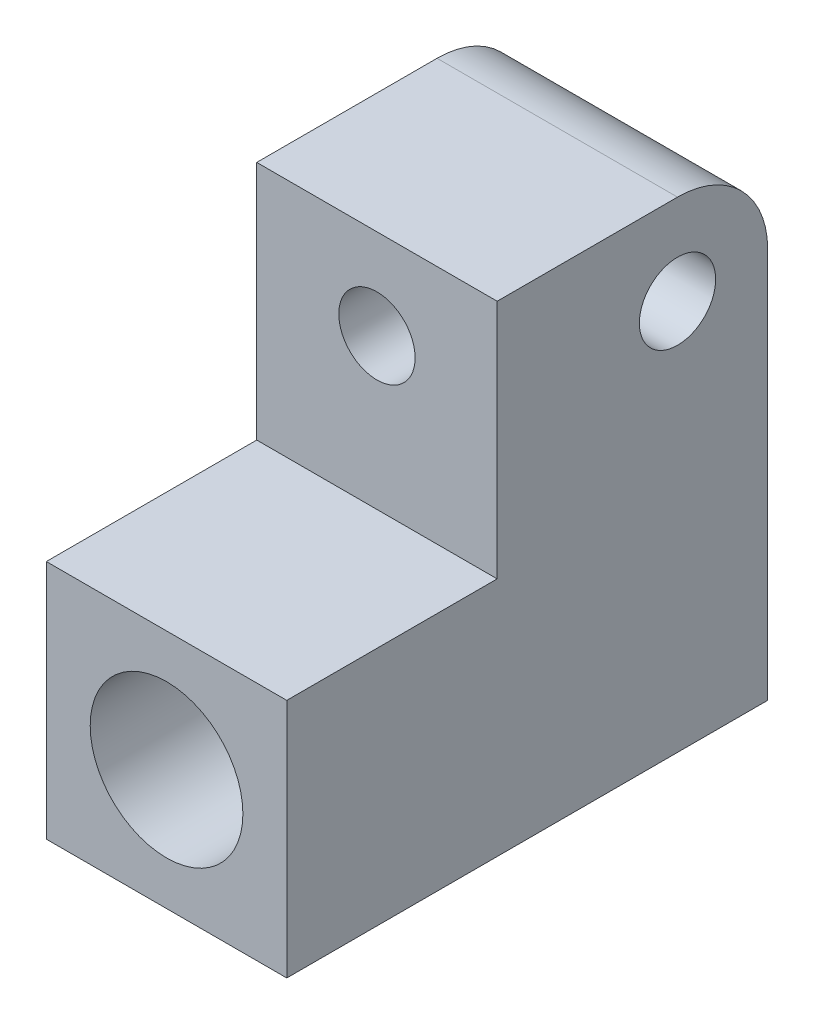
from build123d import *

# Parameters (mm, degrees)
SKETCH3_W           = 20
SKETCH3_H           = 40
BOSS_EXTRUDE2_DEPTH = 20
FILLET2_R           = 7.5
SKETCH4_R           = 3.175
CUT_EXTRUDE2_DEPTH  = 21
SKETCH5_W           = 20
SKETCH5_H           = 17.5
CUT_EXTRUDE3_DEPTH  = 20
CUT_EXTRUDE4_REACH  = 24.5
SKETCH6_R           = 3.175
SKETCH7_R           = 6.35
CUT_EXTRUDE5_DEPTH  = 41


with BuildPart() as part:
    # Sketch3 → Boss-Extrude2 (new body, symmetric)
    with BuildSketch(Plane(origin=(0, 0, 0), x_dir=(1, 0, 0), z_dir=(0, 1, 0))):
        Rectangle(SKETCH3_W, SKETCH3_H)
    extrude(amount=BOSS_EXTRUDE2_DEPTH, both=True)

    # Fillet2
    fillet2_edges = [part.edges().sort_by_distance(p)[0] for p in [
        (0, 20, -20),
    ]]
    fillet(fillet2_edges, radius=FILLET2_R)

    # Sketch4 → Cut-Extrude2 (cut, through all)
    with BuildSketch(Plane.ZY.offset(10)):
        with Locations((-12.5, 12.5)):
            Circle(SKETCH4_R)
    extrude(amount=-CUT_EXTRUDE2_DEPTH, mode=Mode.SUBTRACT)

    # Sketch5 → Cut-Extrude3 (cut)
    with BuildSketch(Plane(origin=(0, 20, 0), x_dir=(1, 0, 0), z_dir=(0, 1, 0))):
        with Locations((0, -11.25)):
            Rectangle(SKETCH5_W, SKETCH5_H)
    extrude(amount=-CUT_EXTRUDE3_DEPTH, mode=Mode.SUBTRACT)

    # Sketch6 → Cut-Extrude4 (cut, up to next)
    with BuildSketch(Plane.XY.offset(2.5), mode=Mode.PRIVATE) as cut_extrude4_sk1:
        with Locations((0, 12.5)):
            Circle(SKETCH6_R)
    cut_extrude4_tool1 = extrude(cut_extrude4_sk1.sketch, amount=-CUT_EXTRUDE4_REACH, mode=Mode.PRIVATE) & part.part
    add(cut_extrude4_tool1.solids().sort_by_distance((0, 12.5, 2.5))[0], mode=Mode.SUBTRACT)

    # Sketch7 → Cut-Extrude5 (cut, through all)
    with BuildSketch(Plane.XY.offset(20)):
        with Locations((0, -10)):
            Circle(SKETCH7_R)
    extrude(amount=-CUT_EXTRUDE5_DEPTH, mode=Mode.SUBTRACT)


solid = part.part
